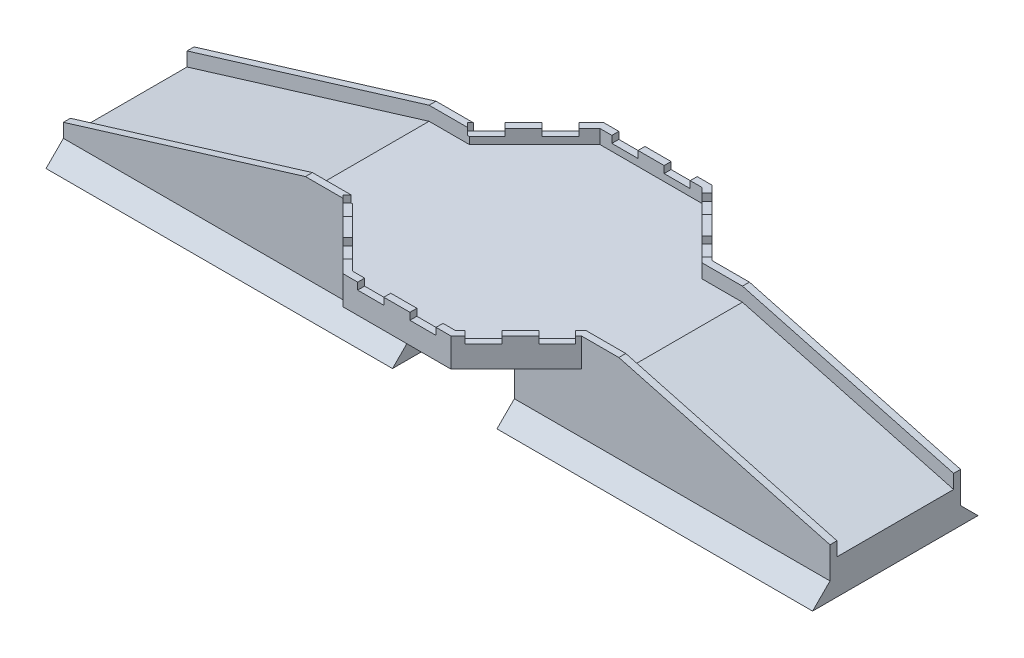
from build123d import *

# Parameters (mm, degrees)
EXTRUDE_1_DEPTH          = 80
EXTRUDE_1_2_DEPTH        = 80
SKETCH_2_W               = 300
SKETCH_2_H               = 80
EXTRUDE_2_DEPTH          = 80
EXTRUDE_3_DEPTH          = 170
EXTRUDE_4_DEPTH          = 1500
EXTRUDE_5_DEPTH          = 80
EXTRUDE_START            = -3980.224726
EXTRUDE_6_DEPTH          = 8806.057751
SKETCH_7_W               = 1200
SKETCH_7_H               = 200
CUT_EXTRUDE_1_DEPTH      = 751
CUT_EXTRUDE_1_DEPTH_BACK = 2251


with BuildPart() as part:
    # 草图1 → 凸台-拉伸1 (new body)
    with BuildSketch(Plane(origin=(0, 0, 0), x_dir=(1, 0, 0), z_dir=(0, 1, 0))):
        Polygon((1371.32034356, 750), (621.32034356, 1500), (-621.32034356, 1500), (-1371.32034356, 750), (-1800, 750), (-1800, 670), (-1338.18325857, 670), (-588.18325857, 1420), (588.18325857, 1420), (1338.18325857, 670), (1800, 670), (1800, 750), align=None)
    extrude(amount=EXTRUDE_1_DEPTH)



with BuildPart() as body_2:
    # 草图1 → Extrude 1 2 (new body)
    with BuildSketch(Plane(origin=(0, 0, 0), x_dir=(1, 0, 0), z_dir=(0, 1, 0))):
        Polygon((-1371.32034356, -750), (-621.32034356, -1500), (621.32034356, -1500), (1371.32034356, -750), (1800, -750), (1800, -670), (1338.18325857, -670), (588.18325857, -1420), (-588.18325857, -1420), (-1338.18325857, -670), (-1800, -670), (-1800, -750), align=None)
    extrude(amount=EXTRUDE_1_2_DEPTH)


with BuildPart() as part_1:
    add(part.part)

    add(body_2.part)  # 凸台-拉伸2 merges body 2
    # 草图2 → 凸台-拉伸2 (add)
    with BuildSketch(Plane(origin=(0, 80, 0), x_dir=(1, 0, 0), z_dir=(0, 1, 0))):
        with Locations((0, -1460)):
            Rectangle(SKETCH_2_W, SKETCH_2_H)
        Polygon((588.18325857, -1420), (450, -1420), (450, -1500), (621.32034356, -1500), (701.553749531, -1419.766594029), (644.985207036, -1363.198051534), align=None)
        Polygon((1125.817818243, -995.502525317), (1069.249275748, -938.933982822), (857.117241392, -1151.066017178), (913.685783887, -1207.634559673), align=None)
        Polygon((1338.18325857, -670), (1281.381310104, -726.801948466), (1337.949852599, -783.370490961), (1371.32034356, -750), (1800, -750), (1800, -670), align=None)
        Polygon((-1371.32034356, -750), (-1403.712468582, -717.607874978), (-1356.104593604, -670), (-1800, -670), (-1800, -750), align=None)
        Polygon((-1132.685863612, -875.497394958), (-1189.254406107, -932.065937453), (-977.122371751, -1144.197971809), (-920.553829256, -1087.629429314), align=None)
        Polygon((-450, -1420), (-588.18325857, -1420), (-708.4217949, -1299.76146367), (-764.990337395, -1356.330006165), (-621.32034356, -1500), (-450, -1500), align=None)
        with Locations((0, 1460)):
            Rectangle(SKETCH_2_W, SKETCH_2_H)
        Polygon((-588.18325857, 1420), (-450, 1420), (-450, 1500), (-621.32034356, 1500), (-764.990337395, 1356.330006165), (-708.4217949, 1299.76146367), align=None)
        Polygon((-1189.254406107, 932.065937453), (-1132.685863612, 875.497394958), (-920.553829256, 1087.629429314), (-977.122371751, 1144.197971809), align=None)
        Polygon((-1800, 670), (-1356.104593604, 670), (-1403.712468582, 717.607874978), (-1371.32034356, 750), (-1800, 750), align=None)
        Polygon((1371.32034356, 750), (1337.949852599, 783.370490961), (1281.381310104, 726.801948466), (1338.18325857, 670), (1800, 670), (1800, 750), align=None)
        Polygon((1069.249275748, 938.933982822), (1125.817818243, 995.502525317), (913.685783887, 1207.634559673), (857.117241392, 1151.066017178), align=None)
        Polygon((450, 1420), (588.18325857, 1420), (644.985207036, 1363.198051534), (701.553749531, 1419.766594029), (621.32034356, 1500), (450, 1500), align=None)
    extrude(amount=EXTRUDE_2_DEPTH)

    # 草图3 → 凸台-拉伸3 (add)
    with BuildSketch(Plane.XZ):
        Polygon((-1800, 750), (-1800, -750), (-1371.32034356, -750), (-621.32034356, -1500), (621.32034356, -1500), (1371.32034356, -750), (1800, -750), (1800, 750), (1371.32034356, 750), (621.32034356, 1500), (-621.32034356, 1500), (-1371.32034356, 750), align=None)
    extrude(amount=EXTRUDE_3_DEPTH)

    # 草图4 → 凸台-拉伸4 (add)
    with BuildSketch(Plane.XY.offset(750)):
        Polygon((-600, 0), (-1800, 0), (-4580.224725712, -850), (-4580.224725712, -1050), (-600, -1050), align=None)
        Polygon((600, 0), (1800, 0), (4225.83302492, -650), (4225.83302492, -1050), (600, -1050), align=None)
    extrude(amount=-EXTRUDE_4_DEPTH)

    # 草图5 → 凸台-拉伸5 (add)
    with BuildSketch(Plane(origin=(0, 0, -750), x_dir=(-1, 0, 0), z_dir=(0, 0, -1))):
        Polygon((-4225.83302492, -650), (-1800, 0), (-1800, 160), (-4225.83302492, -490), align=None)
        Polygon((4580.224725712, -850), (1800, 0), (1800, 160), (4580.224725712, -690), align=None)
    extrude_5 = extrude(amount=-EXTRUDE_5_DEPTH)

    # 镜向1: 凸台-拉伸5 across plane
    add(extrude_5.mirror(Plane.XY))

    # 草图6 → 凸台-拉伸6 (add)
    with BuildSketch(Plane(origin=(-600, 0, 0), x_dir=(0, 0, -1), z_dir=(1, 0, 0)).offset(EXTRUDE_START)):
        Polygon((750, -850), (950, -1050), (-950, -1050), (-750, -850), align=None)
    extrude(amount=EXTRUDE_6_DEPTH)

    # 草图7 → 切除-拉伸1 (cut, two sides)
    with BuildSketch(Plane.XY.offset(750)) as cut_extrude_1_sk:
        with Locations((0, -950)):
            Rectangle(SKETCH_7_W, SKETCH_7_H)
    extrude(amount=CUT_EXTRUDE_1_DEPTH, mode=Mode.SUBTRACT)
    extrude(cut_extrude_1_sk.sketch, amount=-CUT_EXTRUDE_1_DEPTH_BACK, mode=Mode.SUBTRACT)


solid = part_1.part
